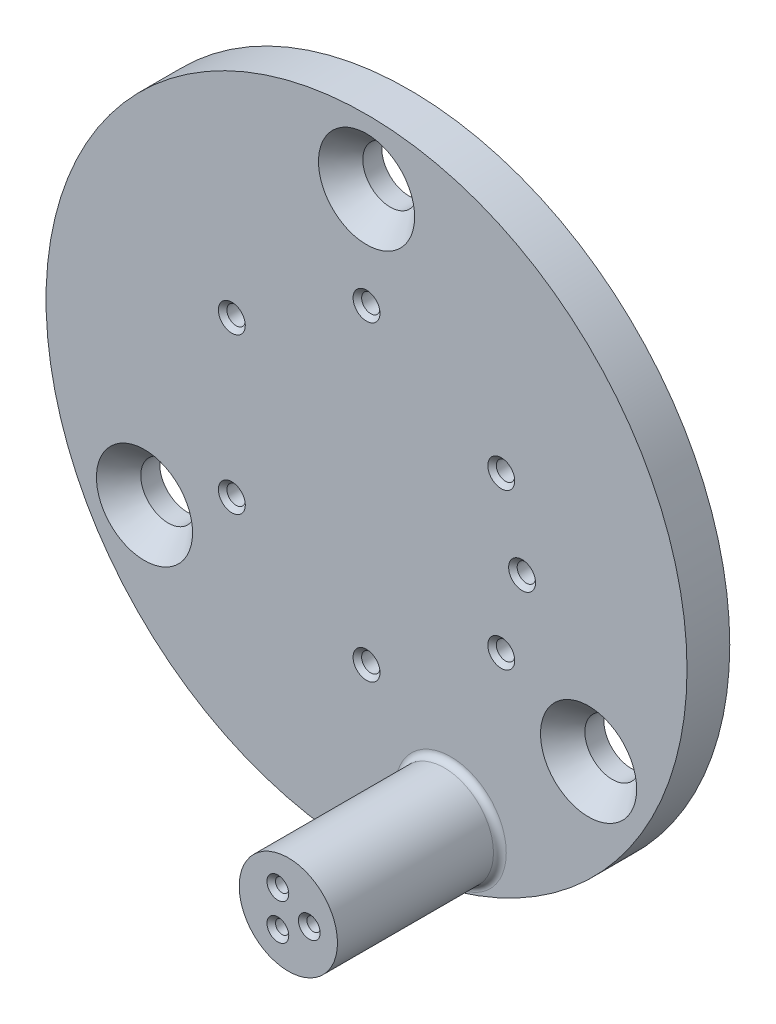
from build123d import *

# Parameters (mm, degrees)
SKETCH1_R                                     = 19.05
BOSS_EXTRUDE1_DEPTH                           = 2.54
CSK_FOR_4_FLAT_HEAD_MACHINE_SCREW1_AT_2_COUNT = 2
CSK_FOR_4_FLAT_HEAD_MACHINE_SCREW1_AT_2_PITCH = 26.396454307
CSK_FOR_4_FLAT_HEAD_MACHINE_SCREW1_AT_3_COUNT = 2
CSK_FOR_4_FLAT_HEAD_MACHINE_SCREW1_AT_3_PITCH = 26.396454307
F_57_0_043_DIAMETER_HOLE1_D                   = 1.0922
SKETCH9_R                                     = 2.921
BOSS_EXTRUDE2_DEPTH                           = 9.652
CHAMFER1_SIZE                                 = 0.254
F_68_0_031_DIAMETER_HOLE2_D                   = 0.7874
CHAMFER2_SIZE                                 = 0.254
CHAMFER3_SIZE                                 = 0.254
FILLET1_R                                     = 0.381


with BuildPart() as part:
    # Sketch1 → Boss-Extrude1 (new body)
    with BuildSketch(Plane.XY):
        with Locations((-17.766231698, -20.016488826)):
            Circle(SKETCH1_R)
    extrude(amount=BOSS_EXTRUDE1_DEPTH)

    # Sketch2 → CSK for #4 Flat Head Machine Screw1 (revolve, cut)
    with BuildSketch(Plane(origin=(-30.964458851, -27.67786205, 2.54), x_dir=(0, -1, 0), z_dir=(1, 0, 0))):
        Polygon((0, 0), (0, 2.54), (1.63195, 2.54), (1.63195, 1.409834001), (2.8575, 0), align=None)
    csk_for_4_flat_head_machine_screw1 = revolve(axis=Axis((-30.964458851, -27.67786205, 8.89), (0, 0, -1)), mode=Mode.SUBTRACT)

    # CSK for #4 Flat Head Machine Screw1 at 2: CSK for #4 Flat Head Machine Screw1 ×2
    with Locations(*[Vector(0.5, 0.866025404, 0) * (i * CSK_FOR_4_FLAT_HEAD_MACHINE_SCREW1_AT_2_PITCH) for i in range(1, CSK_FOR_4_FLAT_HEAD_MACHINE_SCREW1_AT_2_COUNT)]):
        add(csk_for_4_flat_head_machine_screw1, mode=Mode.SUBTRACT)

    # CSK for #4 Flat Head Machine Screw1 at 3: CSK for #4 Flat Head Machine Screw1 ×2
    with Locations(*[(i * CSK_FOR_4_FLAT_HEAD_MACHINE_SCREW1_AT_3_PITCH, 0, 0) for i in range(1, CSK_FOR_4_FLAT_HEAD_MACHINE_SCREW1_AT_3_COUNT)]):
        add(csk_for_4_flat_head_machine_screw1, mode=Mode.SUBTRACT)

    # #57 (0.043) Diameter Hole1 (through all)
    with Locations(Plane.XY.offset(2.54)):
        with Locations((-17.766231698, -10.81226205), (-25.773156171, -15.43506205), (-9.759307225, -15.43506205), (-8.520631698, -20.05786205), (-9.759307225, -24.68066205), (-17.766231698, -29.30346205), (-25.773156171, -24.68066205)):
            Hole(F_57_0_043_DIAMETER_HOLE1_D / 2)

    # Sketch9 → Boss-Extrude2 (add)
    with BuildSketch(Plane.XY.offset(2.54)):
        with Locations((-12.762431698, -34.829926536)):
            Circle(SKETCH9_R)
    extrude(amount=BOSS_EXTRUDE2_DEPTH)

    # Chamfer1
    chamfer1_edges = [part.edges().sort_by_distance(p)[0] for p in [
        (-25.227056171, -24.68066205, 2.54),
        (-17.220131698, -29.30346205, 2.54),
        (-9.213207225, -24.68066205, 2.54),
        (-7.974531698, -20.05786205, 2.54),
        (-9.213207225, -15.43506205, 2.54),
        (-25.227056171, -15.43506205, 2.54),
        (-17.220131698, -10.81226205, 2.54),
    ]]
    chamfer(chamfer1_edges, length=CHAMFER1_SIZE)

    # #68 (0.031) Diameter Hole2 (through all)
    with Locations(Plane.XY.offset(12.192)):
        with Locations((-13.384731698, -33.752071319), (-13.384731698, -35.907781754), (-11.517831698, -34.829926536)):
            Hole(F_68_0_031_DIAMETER_HOLE2_D / 2)

    # Chamfer2
    chamfer2_edges = [part.edges().sort_by_distance(p)[0] for p in [
        (-11.124131698, -34.829926536, 12.192),
        (-12.991031698, -35.907781754, 12.192),
        (-12.991031698, -33.752071319, 12.192),
    ]]
    chamfer(chamfer2_edges, length=CHAMFER2_SIZE)

    # Chamfer3
    chamfer3_edges = [part.edges().sort_by_distance(p)[0] for p in [
        (-25.227056171, -24.68066205, 0),
        (-17.220131698, -29.30346205, 0),
        (-9.213207225, -24.68066205, 0),
        (-7.974531698, -20.05786205, 0),
        (-9.213207225, -15.43506205, 0),
        (-25.227056171, -15.43506205, 0),
        (-17.220131698, -10.81226205, 0),
        (-11.124131698, -34.829926536, 0),
        (-12.991031698, -35.907781754, 0),
        (-12.991031698, -33.752071319, 0),
    ]]
    chamfer(chamfer3_edges, length=CHAMFER3_SIZE)

    # Fillet1
    fillet1_edges = [part.edges().sort_by_distance(p)[0] for p in [
        (-15.683431698, -34.829926536, 2.54),
    ]]
    fillet(fillet1_edges, radius=FILLET1_R)


solid = part.part
